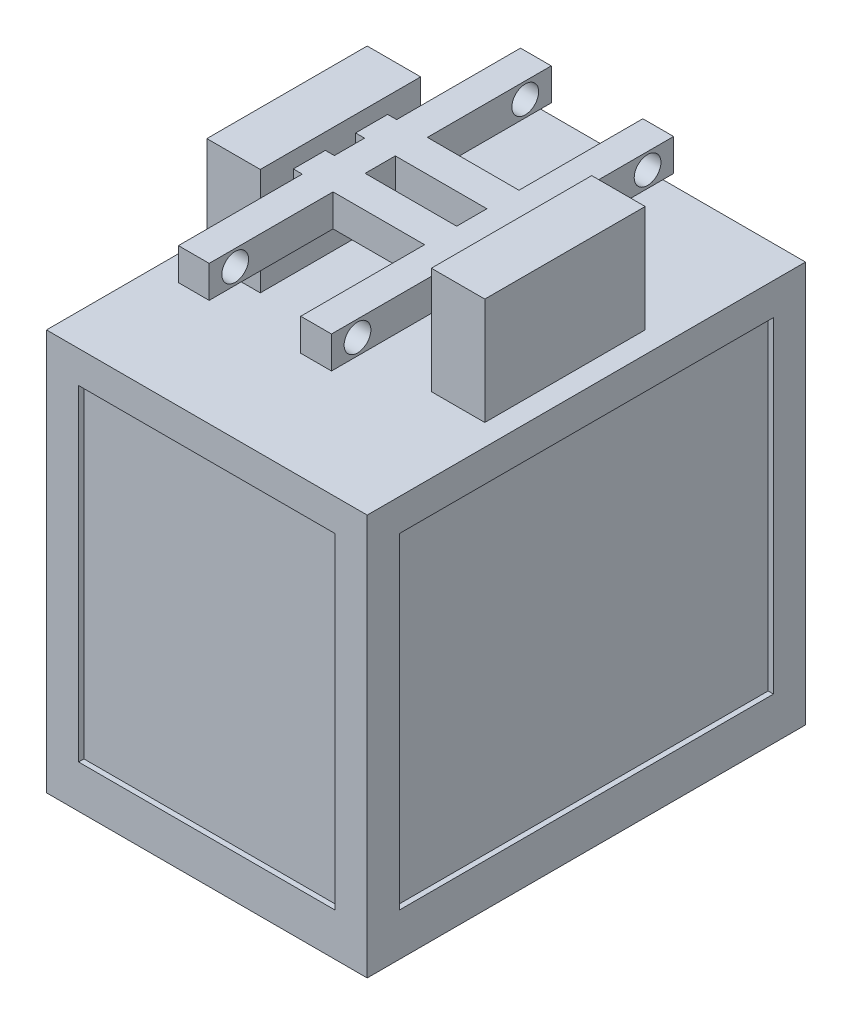
from build123d import *

# Parameters (mm, degrees)
SKETCH2_W            = 480
SKETCH2_H            = 700
BOSS_EXTRUDE1_DEPTH  = 60
SKETCH3_W            = 600
SKETCH3_H            = 820
SKETCH3_W_2          = 480
SKETCH3_H_2          = 700
BOSS_EXTRUDE4_DEPTH  = 80
SKETCH5_W            = 60
SKETCH5_H            = 60
BOSS_EXTRUDE5_DEPTH  = 610
SKETCH7_W            = 600
SKETCH7_H            = 820
BOSS_EXTRUDE6_DEPTH  = 60
BOSS_EXTRUDE7_DEPTH  = 670
SKETCH21_W           = 100
SKETCH21_H           = 300
BOSS_EXTRUDE13_DEPTH = 200
SKETCH28_W           = 60
SKETCH28_H           = 60
BOSS_EXTRUDE18_DEPTH = 520
SKETCH29_W           = 57.5339273
SKETCH29_H           = 60
BOSS_EXTRUDE19_DEPTH = 320
SKETCH30_R           = 25
CUT_EXTRUDE1_DEPTH   = 320


with BuildPart() as part:
    # Sketch2 → Boss-Extrude1 (new body)
    with BuildSketch(Plane(origin=(0, 0, 0), x_dir=(1, 0, 0), z_dir=(0, 1, 0))):
        Rectangle(SKETCH2_W, SKETCH2_H)
    extrude(amount=BOSS_EXTRUDE1_DEPTH)

    # Sketch3 → Boss-Extrude4 (add)
    with BuildSketch(Plane(origin=(0, 0, 0), x_dir=(1, 0, 0), z_dir=(0, 1, 0))):
        Rectangle(SKETCH3_W, SKETCH3_H)
        Rectangle(SKETCH3_W_2, SKETCH3_H_2, mode=Mode.SUBTRACT)
    extrude(amount=BOSS_EXTRUDE4_DEPTH)

    # Sketch5 → Boss-Extrude5 (add)
    with BuildSketch(Plane(origin=(0, 80, 0), x_dir=(1, 0, 0), z_dir=(0, 1, 0))):
        with Locations((270, 380)):
            Rectangle(SKETCH5_W, SKETCH5_H)
        with Locations((-270, 380)):
            Rectangle(SKETCH5_W, SKETCH5_H)
        with Locations((270, -380)):
            Rectangle(SKETCH5_W, SKETCH5_H)
        with Locations((-270, -380)):
            Rectangle(SKETCH5_W, SKETCH5_H)
    extrude(amount=BOSS_EXTRUDE5_DEPTH)

    # Sketch7 → Boss-Extrude6 (add)
    with BuildSketch(Plane(origin=(0, 690, 0), x_dir=(1, 0, 0), z_dir=(0, 1, 0))):
        Rectangle(SKETCH7_W, SKETCH7_H)
    extrude(amount=BOSS_EXTRUDE6_DEPTH)

    # Sketch10 → Boss-Extrude7 (add)
    with BuildSketch(Plane(origin=(0, 80, 0), x_dir=(1, 0, 0), z_dir=(0, 1, 0))):
        Polygon((270, -380), (-270, -380), (-270, 380), (-290, 380), (-290, -400), (290, -400), (290, 380), (270, 380), align=None)
    extrude(amount=BOSS_EXTRUDE7_DEPTH)

    # Sketch21 → Boss-Extrude13 (add)
    with BuildSketch(Plane(origin=(0, 750, 0), x_dir=(1, 0, 0), z_dir=(0, 1, 0))):
        with Locations((-210, 0)):
            Rectangle(SKETCH21_W, SKETCH21_H)
        with Locations((210, 0)):
            Rectangle(SKETCH21_W, SKETCH21_H)
    extrude(amount=BOSS_EXTRUDE13_DEPTH)

    # Sketch28 → Boss-Extrude18 (add)
    with BuildSketch(Plane(origin=(260, 0, 0), x_dir=(0, 0, -1), z_dir=(1, 0, 0))):
        with Locations((58.262274835, 890)):
            Rectangle(SKETCH28_W, SKETCH28_H)
        with Locations((-58.262274835, 890)):
            Rectangle(SKETCH28_W, SKETCH28_H)
    extrude(amount=-BOSS_EXTRUDE18_DEPTH)

    # Sketch29 → Boss-Extrude19 (add, symmetric)
    with BuildSketch(Plane.XY):
        with Locations((-114.414059972, 890)):
            Rectangle(SKETCH29_W, SKETCH29_H)
        with Locations((114.414059972, 890)):
            Rectangle(SKETCH29_W, SKETCH29_H)
    extrude(amount=BOSS_EXTRUDE19_DEPTH, both=True)

    # Sketch30 → Cut-Extrude1 (cut, symmetric)
    with BuildSketch(Plane(origin=(0, 0, 0), x_dir=(0, 0, -1), z_dir=(1, 0, 0))):
        with Locations((-271.32477079, 890)):
            Circle(SKETCH30_R)
        with Locations((271.32477079, 890)):
            Circle(SKETCH30_R)
    extrude(amount=CUT_EXTRUDE1_DEPTH, both=True, mode=Mode.SUBTRACT)


solid = part.part
